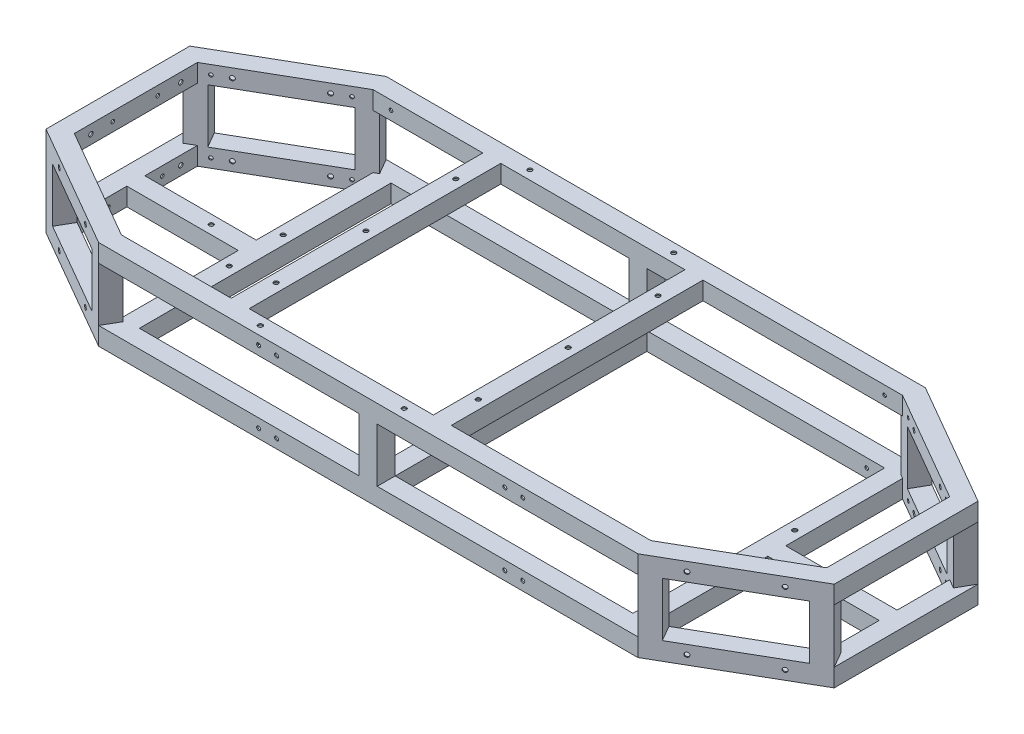
from build123d import *

# Parameters (mm, degrees)
SKETCH2_W                             = 25.4
SKETCH2_H                             = 25.4
SKETCH2_W_2                           = 22.098
SKETCH2_H_2                           = 22.098
VERTICAL_MEMBER_1_DEPTH               = 76.2
VERTICAL_MEMBER_2_DEPTH               = 76.2
VERTICAL_MEMBERS_5_6_7_8_COPY_1_DEPTH = 76.2
VERTICAL_MEMBERS_5_6_7_8_COPY_2_DEPTH = 76.2
SKETCH6_W                             = 25.4
SKETCH6_H                             = 25.4
SKETCH6_W_2                           = 22.098
SKETCH6_H_2                           = 22.098
MIDDLE_VERTICAL_MEMBER_1_DEPTH        = 88.9
MIDDLE_SUPPORT_REACH                  = 383
SKETCH7_W                             = 25.4
SKETCH7_H                             = 25.4
SKETCH7_W_2                           = 22.098
SKETCH7_H_2                           = 22.098
SKETCH8_W                             = 25.4
SKETCH8_H                             = 25.4
SKETCH8_W_2                           = 22.098
SKETCH8_H_2                           = 22.098
BOTTOM_SUPPORT_REAR_DEPTH             = 355.6
SKETCH9_W                             = 25.4
SKETCH9_H                             = 25.4
SKETCH9_W_2                           = 22.098
SKETCH9_H_2                           = 22.098
I_BEAM_DEPTH                          = 157.382272
SKETCH10_W                            = 25.4
SKETCH10_H                            = 25.4
SKETCH10_W_2                          = 22.098
SKETCH10_H_2                          = 22.098
TOP_REAR_SUPPORT_DEPTH                = 355.6
F_1_4_0_25_DIAMETER_HOLE_1_D          = 6.35
F_1_4_0_25_DIAMETER_HOLE_3_AT_2_COUNT = 2
F_1_4_0_25_DIAMETER_HOLE_3_AT_2_PITCH = 203.2
F_1_4_0_25_DIAMETER_HOLE3_AT_2_COUNT  = 2
F_1_4_0_25_DIAMETER_HOLE3_AT_2_PITCH  = 101.6
SKETCH22_R                            = 2.54
INNER_HOLE_LOCATION_1_DEPTH           = 6.35
INNER_HOLE_LOCATION_3_COPY_1_SKETCH_R = 2.54
INNER_HOLE_LOCATION_3_COPY_1_DEPTH    = 6.35
INNER_HOLE_LOCATION_4_COPY_1_SKETCH_R = 2.54
INNER_HOLE_LOCATION_4_COPY_1_DEPTH    = 6.35
INNER_HOLE_LOCATION_4_COPY_2_SKETCH_R = 2.54
INNER_HOLE_LOCATION_4_COPY_2_DEPTH    = 6.35
INNER_HOLE_LOCATION_4_COPY_3_SKETCH_R = 2.54
INNER_HOLE_LOCATION_4_COPY_3_DEPTH    = 6.35
SKETCH23_R                            = 3.175
REAR_SHOCK_MOUNT_HOLES_DEPTH          = 26.4
SKETCH24_R                            = 1.2446
Z_DIRECTION_HOLES_DEPTH               = 1.651
SKETCH25_R                            = 1.2446
X_DIRECTION_HOLES_DEPTH               = 1.651
SKETCH26_R                            = 3.175
REAR_HOLES_DEPTH                      = 25.4
SKETCH27_R                            = 1.2446
CUT_EXTRUDE5_DEPTH                    = 1.651
SKETCH29_R                            = 2.8067
CUT_EXTRUDE7_DEPTH                    = 25.4
SKETCH30_R                            = 2.54
CUT_EXTRUDE8_DEPTH                    = 1.651
SKETCH31_R                            = 2.54
CUT_EXTRUDE9_DEPTH                    = 1.651


with BuildPart() as part:
    # Bottom Frame: sweep along a path in Sketch3
    with BuildLine(Plane(origin=(0, 0, 0), x_dir=(1, 0, 0), z_dir=(0, 1, 0))) as bottom_frame_path:
        Line((-381, 203.2), (381, 203.2))
        Line((381, 203.2), (556.976362049, 101.6))
        Line((556.976362049, 101.6), (556.976362049, -101.6))
        Line((556.976362049, -101.6), (381, -203.2))
        Line((381, -203.2), (-381, -203.2))
        Line((-381, -203.2), (-556.976362049, -101.6))
        Line((-556.976362049, -101.6), (-556.976362049, 101.6))
        Line((-556.976362049, 101.6), (-381, 203.2))
    # Sketch2 → Bottom Frame (sweep)
    with BuildSketch(Plane(origin=(0, 0, 0), x_dir=(0, 0, -1), z_dir=(1, 0, 0))):
        with Locations((190.5, 0)):
            Rectangle(SKETCH2_W, SKETCH2_H)
        with Locations((190.5, 0)):
            Rectangle(SKETCH2_W_2, SKETCH2_H_2, mode=Mode.SUBTRACT)
    bottom_frame = sweep(path=bottom_frame_path.line, transition=Transition.RIGHT)

    # Sketch4 → Vertical Member 1 (add)
    with BuildSketch(Plane(origin=(0, 12.7, 0), x_dir=(1, 0, 0), z_dir=(0, 1, 0))):
        Polygon((-381, -203.2), (-402.997045256, -190.5), (-390.297045256, -168.502954744), (-368.3, -181.202954744), align=None)
        Polygon((-381.604307942, -200.944692058), (-400.741737314, -189.895692058), (-389.692737314, -170.758262686), (-370.555307942, -181.807262686), align=None, mode=Mode.SUBTRACT)
    vertical_member_1 = extrude(amount=VERTICAL_MEMBER_1_DEPTH)

    # Sketch5 → Vertical Member 2 (add)
    with BuildSketch(Plane(origin=(0, 12.7, 0), x_dir=(1, 0, 0), z_dir=(0, 1, 0))):
        Polygon((-556.976362049, -101.6), (-534.979316793, -114.3), (-522.279316793, -92.302954744), (-544.276362049, -79.602954744), align=None)
        Polygon((-554.721054107, -100.995692058), (-535.583624735, -112.044692058), (-524.534624735, -92.907262686), (-543.672054107, -81.858262686), align=None, mode=Mode.SUBTRACT)
    vertical_member_2 = extrude(amount=VERTICAL_MEMBER_2_DEPTH)

    # Vertical Member 3 & 4: Vertical Member 1, Vertical Member 2 across plane
    add(vertical_member_1.mirror(Plane.XY))
    add(vertical_member_2.mirror(Plane.XY))

    # Vertical Members 5, 6, 7, 8: Vertical Member 1, Vertical Member 2 across plane
    add(vertical_member_1.mirror(Plane(origin=(0, 0, 0), x_dir=(0, 0, 1), z_dir=(1, 0, 0))))
    add(vertical_member_2.mirror(Plane(origin=(0, 0, 0), x_dir=(0, 0, 1), z_dir=(1, 0, 0))))

    # Vertical Members 5, 6, 7, 8 copy 1 sketc → Vertical Members 5, 6, 7, 8 copy 1 (add)
    with BuildSketch(Plane(origin=(0, 12.7, 0), x_dir=(-1, 0, 0), z_dir=(0, 1, 0))):
        Polygon((-381, -203.2), (-402.997045256, -190.5), (-390.297045256, -168.502954744), (-368.3, -181.202954744), align=None)
        Polygon((-381.604307942, -200.944692058), (-400.741737314, -189.895692058), (-389.692737314, -170.758262686), (-370.555307942, -181.807262686), align=None, mode=Mode.SUBTRACT)
    extrude(amount=VERTICAL_MEMBERS_5_6_7_8_COPY_1_DEPTH)

    # Vertical Members 5, 6, 7, 8 copy 2 sketc → Vertical Members 5, 6, 7, 8 copy 2 (add)
    with BuildSketch(Plane(origin=(0, 12.7, 0), x_dir=(-1, 0, 0), z_dir=(0, 1, 0))):
        Polygon((-556.976362049, -101.6), (-534.979316793, -114.3), (-522.279316793, -92.302954744), (-544.276362049, -79.602954744), align=None)
        Polygon((-554.721054107, -100.995692058), (-535.583624735, -112.044692058), (-524.534624735, -92.907262686), (-543.672054107, -81.858262686), align=None, mode=Mode.SUBTRACT)
    extrude(amount=VERTICAL_MEMBERS_5_6_7_8_COPY_2_DEPTH)

    # Sketch6 → Middle Vertical Member 1 (add)
    with BuildSketch(Plane(origin=(0, 12.7, 0), x_dir=(1, 0, 0), z_dir=(0, 1, 0))):
        with Locations((0, -190.5)):
            Rectangle(SKETCH6_W, SKETCH6_H)
        with Locations((0, -190.5)):
            Rectangle(SKETCH6_W_2, SKETCH6_H_2, mode=Mode.SUBTRACT)
    middle_vertical_member_1 = extrude(amount=MIDDLE_VERTICAL_MEMBER_1_DEPTH)

    # Middle Vertical Member 2: Middle Vertical Member 1 across plane
    add(middle_vertical_member_1.mirror(Plane.XY))

    # Top Frame: Bottom Frame across plane
    add(bottom_frame.mirror(Plane.ZX.offset(50.8)))

    # Sketch7 → Middle Support (add, up to next)
    with BuildSketch(Plane(origin=(0, 0, 177.8), x_dir=(-1, 0, 0), z_dir=(0, 0, -1)), mode=Mode.PRIVATE) as middle_support_sk1:
        Rectangle(SKETCH7_W, SKETCH7_H)
        Rectangle(SKETCH7_W_2, SKETCH7_H_2, mode=Mode.SUBTRACT)
    middle_support_tool1 = extrude(middle_support_sk1.sketch, amount=MIDDLE_SUPPORT_REACH, mode=Mode.PRIVATE) - part.part
    add(middle_support_tool1.solids().sort_by_distance((0, 12.34079, 177.8))[0])

    # Sketch8 → Bottom Support Rear (add)
    with BuildSketch(Plane(origin=(0, 0, 177.8), x_dir=(-1, 0, 0), z_dir=(0, 0, -1))):
        with Locations((361.494090512, 0)):
            Rectangle(SKETCH8_W, SKETCH8_H)
        with Locations((361.494090512, 0)):
            Rectangle(SKETCH8_W_2, SKETCH8_H_2, mode=Mode.SUBTRACT)
    bottom_support_rear = extrude(amount=BOTTOM_SUPPORT_REAR_DEPTH)

    # Sketch9 → I Beam (add)
    with BuildSketch(Plane(origin=(-531.576362049, 0, 0), x_dir=(0, 0, -1), z_dir=(1, 0, 0))):
        Rectangle(SKETCH9_W, SKETCH9_H)
        Rectangle(SKETCH9_W_2, SKETCH9_H_2, mode=Mode.SUBTRACT)
    i_beam = extrude(amount=I_BEAM_DEPTH)

    # Bottom Support Front w/ I Beam: Bottom Support Rear, I Beam across plane
    add(bottom_support_rear.mirror(Plane(origin=(0, 0, 0), x_dir=(0, 0, 1), z_dir=(1, 0, 0))))
    add(i_beam.mirror(Plane(origin=(0, 0, 0), x_dir=(0, 0, 1), z_dir=(1, 0, 0))))

    # Sketch10 → Top Rear Support (add)
    with BuildSketch(Plane(origin=(0, 0, 177.8), x_dir=(-1, 0, 0), z_dir=(0, 0, -1))):
        with Locations((206.375, 101.6)):
            Rectangle(SKETCH10_W, SKETCH10_H)
        with Locations((206.375, 101.6)):
            Rectangle(SKETCH10_W_2, SKETCH10_H_2, mode=Mode.SUBTRACT)
    top_rear_support = extrude(amount=TOP_REAR_SUPPORT_DEPTH)

    # Top Front Support: Top Rear Support across plane
    add(top_rear_support.mirror(Plane(origin=(-63.5, 0, 0), x_dir=(0, 0, 1), z_dir=(1, 0, 0))))

    # 1/4 (0.25) Diameter Hole 1 (through all)
    with Locations(Plane(origin=(0, 114.3, 0), x_dir=(1, 0, 0), z_dir=(0, 1, 0))):
        with Locations((-206.375, 127), (-206.375, -127), (-206.375, 0)):
            f_1_4_0_25_diameter_hole_1 = Hole(F_1_4_0_25_DIAMETER_HOLE_1_D / 2)

    # 1/4 (0.25) Diameter Hole 2: 1/4 (0.25) Diameter Hole 1 across plane
    add(f_1_4_0_25_diameter_hole_1.mirror(Plane(origin=(-63.5, 0, 0), x_dir=(0, 0, 1), z_dir=(1, 0, 0))), mode=Mode.SUBTRACT)

    # Sketch17 → 1/4 (0.25) Diameter Hole 3 (revolve, cut)
    with BuildSketch(Plane(origin=(-165.1, 114.3, 190.5), x_dir=(0, 0, 1), z_dir=(1, 0, 0))):
        Polygon((0, 0), (0, 52.707732465), (3.175, 50.8), (3.175, 0), align=None)
    f_1_4_0_25_diameter_hole_3 = revolve(axis=Axis((-165.1, 120.65, 190.5), (0, -1, 0)), mode=Mode.SUBTRACT)

    # 1/4 (0.25) Diameter Hole 3 at 2: 1/4 (0.25) Diameter Hole 3 ×2
    with Locations(*[(i * F_1_4_0_25_DIAMETER_HOLE_3_AT_2_PITCH, 0, 0) for i in range(1, F_1_4_0_25_DIAMETER_HOLE_3_AT_2_COUNT)]):
        add(f_1_4_0_25_diameter_hole_3, mode=Mode.SUBTRACT)

    # 1/4 (0.25) Diameter Hole 4: 1/4 (0.25) Diameter Hole 3 across plane
    add(f_1_4_0_25_diameter_hole_3.mirror(Plane.XY), mode=Mode.SUBTRACT)

    # 1/4 (0.25) Diameter Hole 4 copy 1 sketch → 1/4 (0.25) Diameter Hole 4 copy 1 (revolve, cut)
    with BuildSketch(Plane(origin=(38.1, 114.3, -190.5), x_dir=(0, 0, -1), z_dir=(1, 0, 0))):
        Polygon((0, 0), (0, -52.707732465), (3.175, -50.8), (3.175, 0), align=None)
    revolve(axis=Axis((38.1, 120.65, -190.5), (0, 1, 0)), mode=Mode.SUBTRACT)

    # Sketch20 → 1/4 (0.25) Diameter Hole3 (revolve, cut)
    with BuildSketch(Plane(origin=(-512.982271537, 101.6, 127), x_dir=(0.866025404, 0, 0.5), z_dir=(0, 1, 0))):
        Polygon((0, 0), (0, 52.707732465), (3.175, 50.8), (3.175, 0), align=None)
    f_1_4_0_25_diameter_hole3 = revolve(axis=Axis((-516.157271537, 101.6, 132.499261314), (0.5, 0, -0.866025404)), mode=Mode.SUBTRACT)

    # 1/4 (0.25) Diameter Hole3 at 2: 1/4 (0.25) Diameter Hole3 ×2
    with Locations(*[Vector(0.866025404, 0, 0.5) * (i * F_1_4_0_25_DIAMETER_HOLE3_AT_2_PITCH) for i in range(1, F_1_4_0_25_DIAMETER_HOLE3_AT_2_COUNT)]):
        add(f_1_4_0_25_diameter_hole3, mode=Mode.SUBTRACT)

    # Hole Location 1: 1/4 (0.25) Diameter Hole3 across plane
    add(f_1_4_0_25_diameter_hole3.mirror(Plane.ZX.offset(50.8)), mode=Mode.SUBTRACT)

    # Hole Location 1 copy 1 sketch → Hole Location 1 copy 1 (revolve, cut)
    with BuildSketch(Plane(origin=(-424.994090512, 0, 177.8), x_dir=(0.866025404, 0, 0.5), z_dir=(0, -1, 0))):
        Polygon((0, 0), (0, -52.707732465), (3.175, -50.8), (3.175, 0), align=None)
    revolve(axis=Axis((-428.169090512, 0, 183.299261314), (-0.5, 0, 0.866025404)), mode=Mode.SUBTRACT)

    # Hole Location 2: 1/4 (0.25) Diameter Hole3 across plane
    add(f_1_4_0_25_diameter_hole3.mirror(Plane.XY), mode=Mode.SUBTRACT)

    # Hole Location 2 copy 1 sketch → Hole Location 2 copy 1 (revolve, cut)
    with BuildSketch(Plane(origin=(-512.982271537, 0, -127), x_dir=(0.866025404, 0, -0.5), z_dir=(0, -1, 0))):
        Polygon((0, 0), (0, 52.707732465), (3.175, 50.8), (3.175, 0), align=None)
    revolve(axis=Axis((-516.157271537, 0, -132.499261314), (0.5, 0, 0.866025404)), mode=Mode.SUBTRACT)

    # Hole Location 2 copy 2 sketch → Hole Location 2 copy 2 (revolve, cut)
    with BuildSketch(Plane(origin=(-424.994090512, 0, -177.8), x_dir=(0.866025404, 0, -0.5), z_dir=(0, -1, 0))):
        Polygon((0, 0), (0, 52.707732465), (3.175, 50.8), (3.175, 0), align=None)
    revolve(axis=Axis((-428.169090512, 0, -183.299261314), (0.5, 0, 0.866025404)), mode=Mode.SUBTRACT)

    # Hole Location 2 copy 3 sketch → Hole Location 2 copy 3 (revolve, cut)
    with BuildSketch(Plane(origin=(-424.994090512, 101.6, -177.8), x_dir=(0.866025404, 0, -0.5), z_dir=(0, 1, 0))):
        Polygon((0, 0), (0, -52.707732465), (3.175, -50.8), (3.175, 0), align=None)
    revolve(axis=Axis((-428.169090512, 101.6, -183.299261314), (-0.5, 0, -0.866025404)), mode=Mode.SUBTRACT)

    # Hole Location 3: 1/4 (0.25) Diameter Hole3 across plane
    add(f_1_4_0_25_diameter_hole3.mirror(Plane(origin=(0, 0, 0), x_dir=(0, 0, 1), z_dir=(1, 0, 0))), mode=Mode.SUBTRACT)

    # Hole Location 3 copy 1 sketch → Hole Location 3 copy 1 (revolve, cut)
    with BuildSketch(Plane(origin=(512.982271537, 101.6, -127), x_dir=(-0.866025404, 0, -0.5), z_dir=(0, 1, 0))):
        Polygon((0, 0), (0, 52.707732465), (3.175, 50.8), (3.175, 0), align=None)
    revolve(axis=Axis((516.157271537, 101.6, -132.499261314), (-0.5, 0, 0.866025404)), mode=Mode.SUBTRACT)

    # Hole Location 3 copy 2 sketch → Hole Location 3 copy 2 (revolve, cut)
    with BuildSketch(Plane(origin=(512.982271537, 0, -127), x_dir=(-0.866025404, 0, -0.5), z_dir=(0, -1, 0))):
        Polygon((0, 0), (0, -52.707732465), (3.175, -50.8), (3.175, 0), align=None)
    revolve(axis=Axis((516.157271537, 0, -132.499261314), (0.5, 0, -0.866025404)), mode=Mode.SUBTRACT)

    # Hole Location 3 copy 3 sketch → Hole Location 3 copy 3 (revolve, cut)
    with BuildSketch(Plane(origin=(424.994090512, 0, -177.8), x_dir=(-0.866025404, 0, -0.5), z_dir=(0, -1, 0))):
        Polygon((0, 0), (0, -52.707732465), (3.175, -50.8), (3.175, 0), align=None)
    revolve(axis=Axis((428.169090512, 0, -183.299261314), (0.5, 0, -0.866025404)), mode=Mode.SUBTRACT)

    # Hole Location 3 copy 4 sketch → Hole Location 3 copy 4 (revolve, cut)
    with BuildSketch(Plane(origin=(424.994090512, 101.6, -177.8), x_dir=(-0.866025404, 0, -0.5), z_dir=(0, 1, 0))):
        Polygon((0, 0), (0, 52.707732465), (3.175, 50.8), (3.175, 0), align=None)
    revolve(axis=Axis((428.169090512, 101.6, -183.299261314), (-0.5, 0, 0.866025404)), mode=Mode.SUBTRACT)

    # Hole Location 3 copy 5 sketch → Hole Location 3 copy 5 (revolve, cut)
    with BuildSketch(Plane(origin=(424.994090512, 101.6, 177.8), x_dir=(-0.866025404, 0, 0.5), z_dir=(0, 1, 0))):
        Polygon((0, 0), (0, -52.707732465), (3.175, -50.8), (3.175, 0), align=None)
    revolve(axis=Axis((428.169090512, 101.6, 183.299261314), (0.5, 0, 0.866025404)), mode=Mode.SUBTRACT)

    # Hole Location 3 copy 6 sketch → Hole Location 3 copy 6 (revolve, cut)
    with BuildSketch(Plane(origin=(512.982271537, 0, 127), x_dir=(-0.866025404, 0, 0.5), z_dir=(0, -1, 0))):
        Polygon((0, 0), (0, 52.707732465), (3.175, 50.8), (3.175, 0), align=None)
    revolve(axis=Axis((516.157271537, 0, 132.499261314), (-0.5, 0, -0.866025404)), mode=Mode.SUBTRACT)

    # Hole Location 3 copy 7 sketch → Hole Location 3 copy 7 (revolve, cut)
    with BuildSketch(Plane(origin=(424.994090512, 0, 177.8), x_dir=(-0.866025404, 0, 0.5), z_dir=(0, -1, 0))):
        Polygon((0, 0), (0, 52.707732465), (3.175, 50.8), (3.175, 0), align=None)
    revolve(axis=Axis((428.169090512, 0, 183.299261314), (-0.5, 0, -0.866025404)), mode=Mode.SUBTRACT)

    # Sketch22 → Inner Hole Location 1 (cut)
    with BuildSketch(Plane(origin=(-170.538181024, 0, -295.380794165), x_dir=(0.866025404, 0, -0.5), z_dir=(0.5, 0, 0.866025404))):
        with Locations((-402.980678842, 101.6)):
            Circle(SKETCH22_R)
        with Locations((-256.930678842, 101.6)):
            Circle(SKETCH22_R)
    inner_hole_location_1 = extrude(amount=-INNER_HOLE_LOCATION_1_DEPTH, mode=Mode.SUBTRACT)

    # Inner Hole Location 2: Inner Hole Location 1 across plane
    add(inner_hole_location_1.mirror(Plane.ZX.offset(50.8)), mode=Mode.SUBTRACT)

    # Inner Hole Location 3: Inner Hole Location 1 across plane
    add(inner_hole_location_1.mirror(Plane.XY), mode=Mode.SUBTRACT)

    # Inner Hole Location 3 copy 1 sketch → Inner Hole Location 3 copy 1 (cut)
    with BuildSketch(Plane(origin=(-170.538181024, 101.6, 295.380794165), x_dir=(0.866025404, 0, 0.5), z_dir=(0.5, 0, -0.866025404))):
        with Locations((-402.980678842, 101.6)):
            Circle(INNER_HOLE_LOCATION_3_COPY_1_SKETCH_R)
        with Locations((-256.930678842, 101.6)):
            Circle(INNER_HOLE_LOCATION_3_COPY_1_SKETCH_R)
    extrude(amount=-INNER_HOLE_LOCATION_3_COPY_1_DEPTH, mode=Mode.SUBTRACT)

    # Inner Hole Location 4: Inner Hole Location 1 across plane
    add(inner_hole_location_1.mirror(Plane(origin=(0, 0, 0), x_dir=(0, 0, 1), z_dir=(1, 0, 0))), mode=Mode.SUBTRACT)

    # Inner Hole Location 4 copy 1 sketch → Inner Hole Location 4 copy 1 (cut)
    with BuildSketch(Plane(origin=(170.538181024, 0, 295.380794165), x_dir=(-0.866025404, 0, 0.5), z_dir=(-0.5, 0, -0.866025404))):
        with Locations((-402.980678842, 101.6)):
            Circle(INNER_HOLE_LOCATION_4_COPY_1_SKETCH_R)
        with Locations((-256.930678842, 101.6)):
            Circle(INNER_HOLE_LOCATION_4_COPY_1_SKETCH_R)
    extrude(amount=-INNER_HOLE_LOCATION_4_COPY_1_DEPTH, mode=Mode.SUBTRACT)

    # Inner Hole Location 4 copy 2 sketch → Inner Hole Location 4 copy 2 (cut)
    with BuildSketch(Plane(origin=(170.538181024, 101.6, 295.380794165), x_dir=(-0.866025404, 0, 0.5), z_dir=(-0.5, 0, -0.866025404))):
        with Locations((-402.980678842, -101.6)):
            Circle(INNER_HOLE_LOCATION_4_COPY_2_SKETCH_R)
        with Locations((-256.930678842, -101.6)):
            Circle(INNER_HOLE_LOCATION_4_COPY_2_SKETCH_R)
    extrude(amount=-INNER_HOLE_LOCATION_4_COPY_2_DEPTH, mode=Mode.SUBTRACT)

    # Inner Hole Location 4 copy 3 sketch → Inner Hole Location 4 copy 3 (cut)
    with BuildSketch(Plane(origin=(170.538181024, 101.6, -295.380794165), x_dir=(-0.866025404, 0, -0.5), z_dir=(-0.5, 0, 0.866025404))):
        with Locations((-402.980678842, 101.6)):
            Circle(INNER_HOLE_LOCATION_4_COPY_3_SKETCH_R)
        with Locations((-256.930678842, 101.6)):
            Circle(INNER_HOLE_LOCATION_4_COPY_3_SKETCH_R)
    extrude(amount=-INNER_HOLE_LOCATION_4_COPY_3_DEPTH, mode=Mode.SUBTRACT)

    # Sketch23 → Rear Shock Mount Holes (cut, through all)
    with BuildSketch(Plane(origin=(0, 12.7, 0), x_dir=(1, 0, 0), z_dir=(0, 1, 0))):
        with Locations((-424.994090512, 0)):
            Circle(SKETCH23_R)
        with Locations((-361.494090512, -38.1)):
            Circle(SKETCH23_R)
        with Locations((-361.494090512, 38.1)):
            Circle(SKETCH23_R)
    rear_shock_mount_holes = extrude(amount=-REAR_SHOCK_MOUNT_HOLES_DEPTH, mode=Mode.SUBTRACT)

    # Front Shock Mount Holes: Rear Shock Mount Holes across plane
    add(rear_shock_mount_holes.mirror(Plane(origin=(0, 0, 0), x_dir=(0, 0, 1), z_dir=(1, 0, 0))), mode=Mode.SUBTRACT)

    # Sketch24 → Z Direction Holes (cut)
    with BuildSketch(Plane.XZ.offset(-88.9)):
        with Locations((-206.375, 139.7)):
            Circle(SKETCH24_R)
        with Locations((-206.375, 114.3)):
            Circle(SKETCH24_R)
        with Locations((-206.375, 12.7)):
            Circle(SKETCH24_R)
        with Locations((-206.375, -12.7)):
            Circle(SKETCH24_R)
        with Locations((-206.375, -114.3)):
            Circle(SKETCH24_R)
        with Locations((-206.375, -139.7)):
            Circle(SKETCH24_R)
        with Locations((79.375, 139.7)):
            Circle(SKETCH24_R)
        with Locations((79.375, 114.3)):
            Circle(SKETCH24_R)
        with Locations((79.375, 12.7)):
            Circle(SKETCH24_R)
        with Locations((79.375, -12.7)):
            Circle(SKETCH24_R)
        with Locations((79.375, -114.3)):
            Circle(SKETCH24_R)
        with Locations((79.375, -139.7)):
            Circle(SKETCH24_R)
    extrude(amount=-Z_DIRECTION_HOLES_DEPTH, mode=Mode.SUBTRACT)

    # Sketch25 → X Direction Holes (cut)
    with BuildSketch(Plane.XZ.offset(-88.9)):
        with Locations((-152.4, -190.5)):
            Circle(SKETCH25_R)
        with Locations((-177.8, -190.5)):
            Circle(SKETCH25_R)
        with Locations((50.8, -190.5)):
            Circle(SKETCH25_R)
        with Locations((25.4, -190.5)):
            Circle(SKETCH25_R)
        with Locations((50.8, 190.5)):
            Circle(SKETCH25_R)
        with Locations((25.4, 190.5)):
            Circle(SKETCH25_R)
        with Locations((-177.8, 190.5)):
            Circle(SKETCH25_R)
        with Locations((-152.4, 190.5)):
            Circle(SKETCH25_R)
    extrude(amount=-X_DIRECTION_HOLES_DEPTH, mode=Mode.SUBTRACT)

    # Sketch26 → Rear Holes (cut)
    with BuildSketch(Plane.ZY.offset(556.976362049)):
        with Locations((-63.5, 101.6)):
            Circle(SKETCH26_R)
        with Locations((63.5, 101.6)):
            Circle(SKETCH26_R)
        with Locations((63.5, 0)):
            Circle(SKETCH26_R)
        with Locations((-63.5, 0)):
            Circle(SKETCH26_R)
    extrude(amount=-REAR_HOLES_DEPTH, mode=Mode.SUBTRACT)

    # Sketch27 → Cut-Extrude5 (cut)
    with BuildSketch(Plane.XZ.offset(12.7)):
        with Locations((-361.442, -190.5)):
            Circle(SKETCH27_R)
        with Locations((-243.078, -190.5)):
            Circle(SKETCH27_R)
        with Locations((-121.666, -190.5)):
            Circle(SKETCH27_R)
        with Locations((0, -190.5)):
            Circle(SKETCH27_R)
        with Locations((121.666, -190.5)):
            Circle(SKETCH27_R)
        with Locations((243.078, -190.5)):
            Circle(SKETCH27_R)
        with Locations((361.442, -190.5)):
            Circle(SKETCH27_R)
        with Locations((-544.276362049, -94.234)):
            Circle(SKETCH27_R)
        with Locations((544.276362049, -94.234)):
            Circle(SKETCH27_R)
        with Locations((544.276362049, 94.234)):
            Circle(SKETCH27_R)
        with Locations((361.442, 190.5)):
            Circle(SKETCH27_R)
        with Locations((243.078, 190.5)):
            Circle(SKETCH27_R)
        with Locations((121.666, 190.5)):
            Circle(SKETCH27_R)
        with Locations((0, 190.5)):
            Circle(SKETCH27_R)
        with Locations((-121.666, 190.5)):
            Circle(SKETCH27_R)
        with Locations((-243.078, 190.5)):
            Circle(SKETCH27_R)
        with Locations((-361.442, 190.5)):
            Circle(SKETCH27_R)
        with Locations((-544.276362049, 94.234)):
            Circle(SKETCH27_R)
    extrude(amount=-CUT_EXTRUDE5_DEPTH, mode=Mode.SUBTRACT)

    # Sketch29 → Cut-Extrude7 (cut)
    with BuildSketch(Plane.XY.offset(203.2)):
        with Locations((-154.94, 101.6)):
            Circle(SKETCH29_R)
        with Locations((-129.54, 101.6)):
            Circle(SKETCH29_R)
        with Locations((-154.94, 0)):
            Circle(SKETCH29_R)
        with Locations((-129.54, 0)):
            Circle(SKETCH29_R)
        with Locations((193.04, 101.6)):
            Circle(SKETCH29_R)
        with Locations((218.44, 101.6)):
            Circle(SKETCH29_R)
        with Locations((193.04, 0)):
            Circle(SKETCH29_R)
        with Locations((218.44, 0)):
            Circle(SKETCH29_R)
    extrude(amount=-CUT_EXTRUDE7_DEPTH, mode=Mode.SUBTRACT)

    # Sketch30 → Cut-Extrude8 (cut)
    with BuildSketch(Plane.XY.offset(-177.8)):
        with Locations((348.794090512, 101.6)):
            Circle(SKETCH30_R)
        with Locations((-348.794090512, 101.6)):
            Circle(SKETCH30_R)
        with Locations((-323.394090512, 0)):
            Circle(SKETCH30_R)
        with Locations((323.394090512, 0)):
            Circle(SKETCH30_R)
    cut_extrude8 = extrude(amount=-CUT_EXTRUDE8_DEPTH, mode=Mode.SUBTRACT)

    # Mirror1: Cut-Extrude8 across plane
    add(cut_extrude8.mirror(Plane.XY), mode=Mode.SUBTRACT)

    # Sketch31 → Cut-Extrude9 (cut)
    with BuildSketch(Plane(origin=(-531.576362049, 0, 0), x_dir=(0, 0, -1), z_dir=(1, 0, 0))):
        with Locations((-32.579303163, 101.6)):
            Circle(SKETCH31_R)
        with Locations((30.920696837, 101.6)):
            Circle(SKETCH31_R)
        with Locations((-38.929303163, 0)):
            Circle(SKETCH31_R)
        with Locations((37.270696837, 0)):
            Circle(SKETCH31_R)
    cut_extrude9 = extrude(amount=-CUT_EXTRUDE9_DEPTH, mode=Mode.SUBTRACT)

    # Mirror2: Cut-Extrude9 across plane
    add(cut_extrude9.mirror(Plane(origin=(0, 0, 0), x_dir=(0, 0, 1), z_dir=(1, 0, 0))), mode=Mode.SUBTRACT)


solid = part.part
